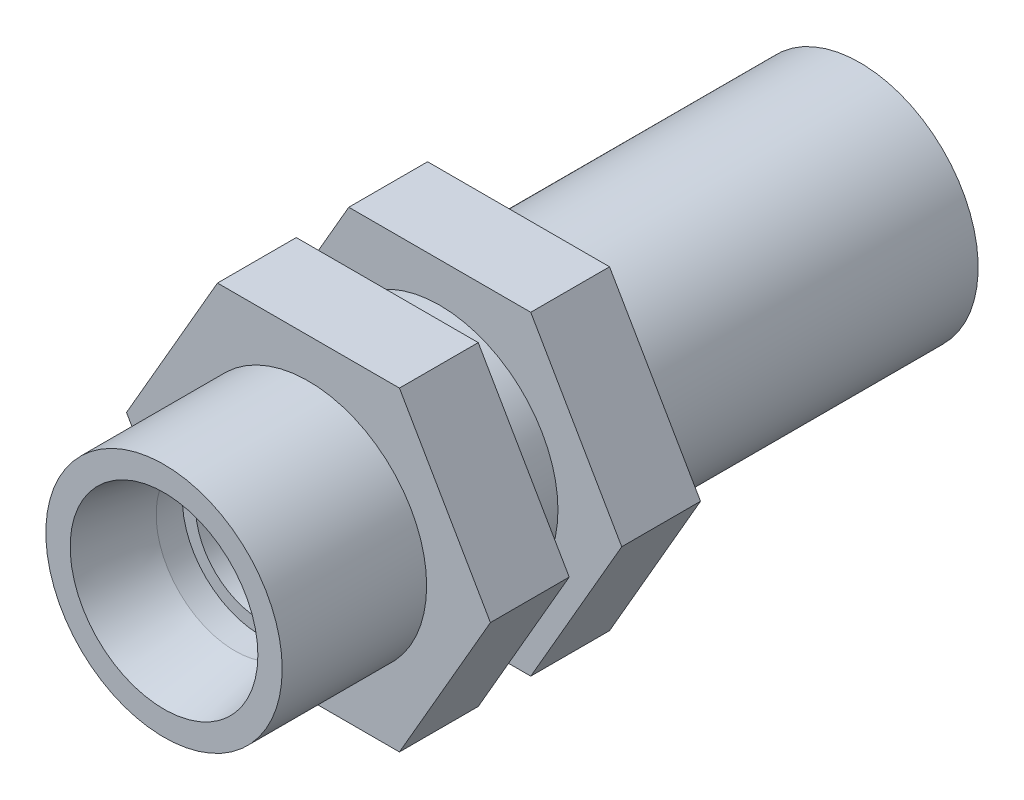
from build123d import *

# Parameters (mm, degrees)
BASE_EXTRUDE_DEPTH  = 6
SKETCH2_R           = 9
BOSS_EXTRUDE1_DEPTH = 11
SKETCH3_R           = 9
BOSS_EXTRUDE2_DEPTH = 4
BOSS_EXTRUDE3_DEPTH = 6
SKETCH5_R           = 9
BOSS_EXTRUDE4_DEPTH = 26


with BuildPart() as part:
    # Sketch1 → Base-Extrude (new body)
    with BuildSketch(Plane.XY):
        Polygon((13.856406461, 0), (6.92820323, 12), (-6.92820323, 12), (-13.856406461, 0), (-6.92820323, -12), (6.92820323, -12), align=None)
    extrude(amount=BASE_EXTRUDE_DEPTH)

    # Sketch2 → Boss-Extrude1 (add)
    with BuildSketch(Plane.XY.offset(6)):
        Circle(SKETCH2_R)
    extrude(amount=BOSS_EXTRUDE1_DEPTH)

    # Sketch3 → Boss-Extrude2 (add)
    with BuildSketch(Plane(origin=(0, 0, 0), x_dir=(-1, 0, 0), z_dir=(0, 0, -1))):
        Circle(SKETCH3_R)
    extrude(amount=BOSS_EXTRUDE2_DEPTH)

    # Sketch4 → Boss-Extrude3 (add)
    with BuildSketch(Plane(origin=(0, 0, -4), x_dir=(-1, 0, 0), z_dir=(0, 0, -1))):
        Polygon((13.856406461, 0), (6.92820323, 12), (-6.92820323, 12), (-13.856406461, 0), (-6.92820323, -12), (6.92820323, -12), align=None)
    extrude(amount=BOSS_EXTRUDE3_DEPTH)

    # Sketch5 → Boss-Extrude4 (add)
    with BuildSketch(Plane(origin=(0, 0, -10), x_dir=(-1, 0, 0), z_dir=(0, 0, -1))):
        Circle(SKETCH5_R)
    extrude(amount=BOSS_EXTRUDE4_DEPTH)

    # Sketch8 → Cut-Revolve1 (revolve, cut)
    with BuildSketch(Plane(origin=(0, 0, 0), x_dir=(0, 0, -1), z_dir=(1, 0, 0))):
        Polygon((36, 0), (36, 7.147805433), (30.6, 6), (28.6, 6), (28.6, 5), (-9.6, 5), (-9.6, 6), (-11.6, 6), (-17, 7.147805433), (-17, 0), align=None)
    revolve(axis=Axis((0, 0, 19), (0, 0, -1)), mode=Mode.SUBTRACT)


solid = part.part
